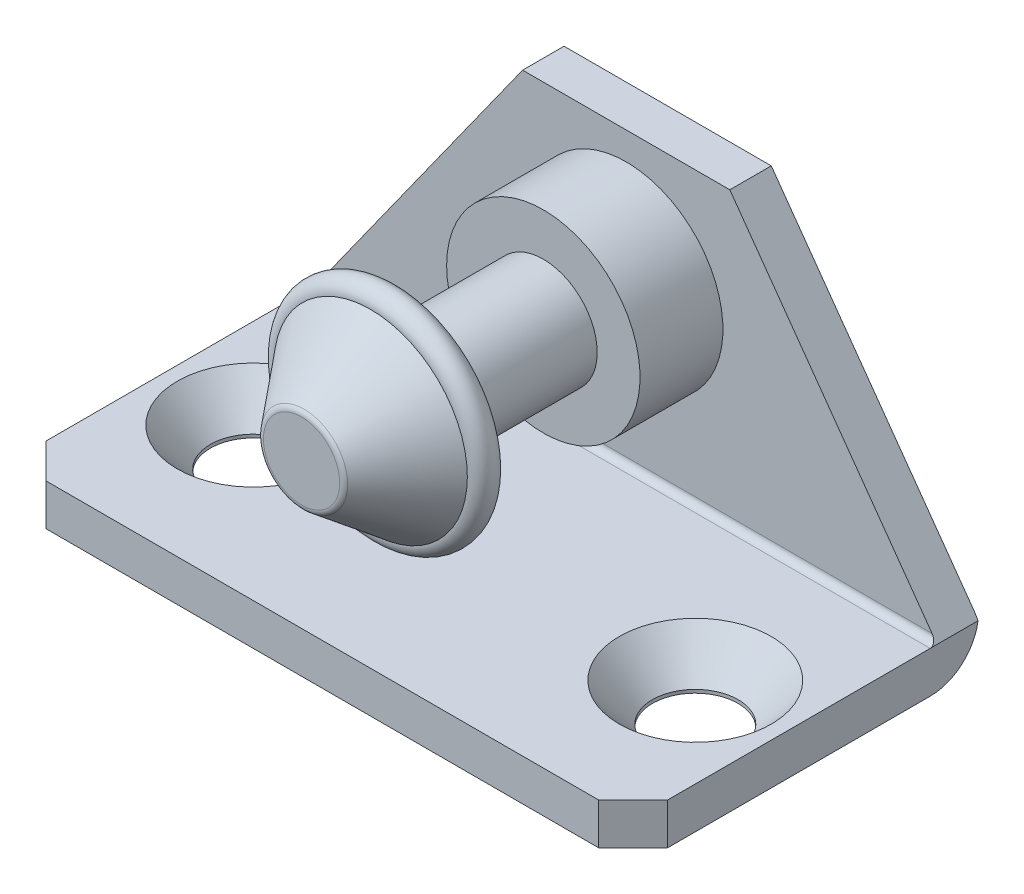
from build123d import *

# Parameters (mm, degrees)
SKETCH1_W        = 45
SKETCH1_H        = 25
EXTRUDE1_DEPTH   = 3
EXTRUDE7_DEPTH   = 3
FILLET3_R        = 0.5
FILLET4_R        = 3.5
HOLE1_AT_2_COUNT = 2
HOLE1_AT_2_PITCH = 32
SKETCH4_R        = 7
EXTRUDE2_DEPTH   = 6
SKETCH5_R        = 3.9
EXTRUDE3_DEPTH   = 10.5
SKETCH6_R        = 3
EXTRUDE4_DEPTH   = 1.4
SKETCH7_R        = 3.9
EXTRUDE6_DEPTH   = 3.1
CHAMFER2_SIZE    = 1
FILLET1_R        = 0.5
CHAMFER1_SIZE    = 2.5


with BuildPart() as part:
    # Sketch1 → Extrude1 (new body)
    with BuildSketch(Plane(origin=(0, 0, 0), x_dir=(1, 0, 0), z_dir=(0, 1, 0))):
        with Locations((0, -12.5)):
            Rectangle(SKETCH1_W, SKETCH1_H)
    extrude(amount=EXTRUDE1_DEPTH)

    # Sketch12 → Extrude7 (add)
    with BuildSketch(Plane.XY):
        Polygon((22.5, 3), (7.5, 24), (-7.5, 24), (-22.5, 3), align=None)
    extrude(amount=EXTRUDE7_DEPTH)

    # Fillet3
    fillet3_edges = [part.edges().sort_by_distance(p)[0] for p in [
        (0, 3, 3),
    ]]
    fillet(fillet3_edges, radius=FILLET3_R)

    # Fillet4
    fillet4_edges = [part.edges().sort_by_distance(p)[0] for p in [
        (0, 0, 0),
    ]]
    fillet(fillet4_edges, radius=FILLET4_R)

    # Sketch2 → Hole1 (revolve, cut)
    with BuildSketch(Plane(origin=(16, 3, 14), x_dir=(0, 0, 1), z_dir=(1, 0, 0))):
        Polygon((0, 0), (0, 3), (3.1, 3), (3.1, 2.760884177), (5.5, 0), align=None)
    hole1 = revolve(axis=Axis((16, 9.445314094, 14), (0, -1, 0)), mode=Mode.SUBTRACT)

    # Hole1 at 2: Hole1 ×2
    with Locations(*[(-i * HOLE1_AT_2_PITCH, 0, 0) for i in range(1, HOLE1_AT_2_COUNT)]):
        add(hole1, mode=Mode.SUBTRACT)

    # Sketch4 → Extrude2 (add)
    with BuildSketch(Plane(origin=(0, 0, 3), x_dir=(-1, 0, 0), z_dir=(0, 0, -1))):
        with Locations((0, 15)):
            Circle(SKETCH4_R)
    extrude(amount=-EXTRUDE2_DEPTH)

    # Sketch5 → Extrude3 (add)
    with BuildSketch(Plane(origin=(0, 0, 9), x_dir=(-1, 0, 0), z_dir=(0, 0, 1))):
        with Locations(Location((0, -15, 0), (0, 0, 270))):
            Circle(SKETCH5_R)
    extrude(amount=EXTRUDE3_DEPTH)

    # Sketch6 → Extrude4 (add)
    with BuildSketch(Plane(origin=(0, 0, 19.5), x_dir=(-1, 0, 0), z_dir=(0, 0, 1))):
        with Locations(Location((0, -15, 0), (0, 0, 90))):
            Circle(SKETCH6_R)
    extrude(amount=EXTRUDE4_DEPTH)

    # Sketch7 → Extrude6 (add)
    with BuildSketch(Plane(origin=(0, 0, 20.9), x_dir=(-1, 0, 0), z_dir=(0, 0, 1))):
        with Locations(Location((0, -15, 0), (0, 0, 270))):
            Circle(SKETCH7_R)
    extrude(amount=EXTRUDE6_DEPTH)

    # Chamfer2
    chamfer2_edges = [part.edges().sort_by_distance(p)[0] for p in [
        (0, 11.1, 24),
    ]]
    chamfer(chamfer2_edges, length=CHAMFER2_SIZE)

    # Chamfer1
    chamfer1_edges = [part.edges().sort_by_distance(p)[0] for p in [
        (22.5, 1.5, 25),
        (-22.5, 1.5, 25),
    ]]
    chamfer(chamfer1_edges, length=CHAMFER1_SIZE)


with BuildPart() as body_2:
    # Sketch8 → Revolve1 (revolve)
    with BuildSketch(Plane(origin=(0, 15, 0), x_dir=(1, 0, 0), z_dir=(0, 1, 0)), mode=Mode.PRIVATE) as revolve1_sk:
        with BuildLine():
            Line((-7, -21.5), (-3, -26.5))
            Line((-3, -26.5), (0, -26.5))
            Line((0, -26.5), (0, -23.85))
            Line((0, -23.85), (-4.125, -23.85))
            Line((-4.125, -23.85), (-4.125, -19.5))
            Line((-4.125, -19.5), (-7, -19.5))
            ThreePointArc((-7, -19.5), (-8, -20.5), (-7, -21.5))
        make_face()
    revolve(revolve1_sk.sketch.rotate(Axis((0, 15, 19.5), (0, 0, -1)), 180), axis=Axis((0, 15, 19.5), (0, 0, -1)))

    # Fillet1
    fillet1_edges = [body_2.edges().sort_by_distance(p)[0] for p in [
        (-3, 15, 26.5),
    ]]
    fillet(fillet1_edges, radius=FILLET1_R)


solid = Compound([part.part, body_2.part])
